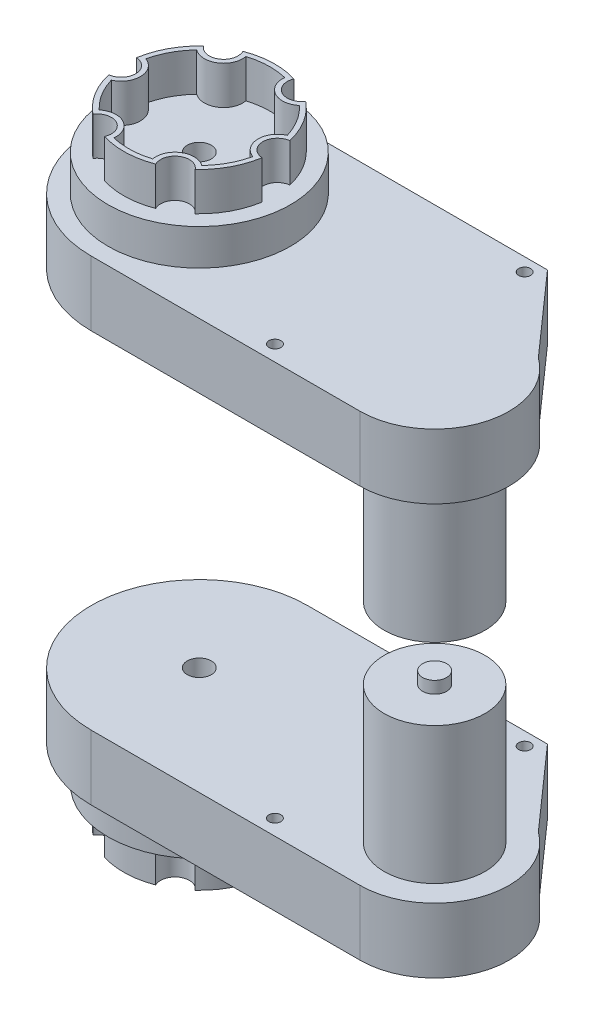
from build123d import *

# Parameters (mm, degrees)
SKETCH1_R                = 2.5
SKETCH1_R_2              = 5
BOSS_EXTRUDE1_DEPTH      = 27
SKETCH2_R                = 21
BOSS_EXTRUDE2_DEPTH      = 57
SKETCH4_R                = 38
SKETCH4_R_2              = 33
BOSS_EXTRUDE3_DEPTH      = 15
BOSS_EXTRUDE4_DEPTH      = 16
BOSS_EXTRUDE4_DEPTH_BACK = 15
SKETCH6_R                = 5
BOSS_EXTRUDE5_DEPTH      = 5
SKETCH7_R                = 33
BOSS_EXTRUDE6_DEPTH      = 15
SKETCH8_R                = 5
CUT_EXTRUDE1_DEPTH       = 65


with BuildPart() as part:
    # Sketch1 → Boss-Extrude1 (new body)
    with BuildSketch(Plane(origin=(0, 0, 0), x_dir=(1, 0, 0), z_dir=(0, 1, 0))):
        with BuildLine():
            Line((100, 45), (0, 45))
            ThreePointArc((0, 45), (-45, 0), (0, -45))
            Line((0, -45), (112, -45))
            ThreePointArc((112, -45), (141.550203848, -23.369389122), (129.862410225, 11.336422419))
            Line((129.862410225, 11.336422419), (100, 45))
        make_face()
        with Locations((70, -38.5)):
            Circle(SKETCH1_R, mode=Mode.SUBTRACT)
        with Locations((96, 39.5)):
            Circle(SKETCH1_R, mode=Mode.SUBTRACT)
        Circle(SKETCH1_R_2, mode=Mode.SUBTRACT)
    extrude(amount=BOSS_EXTRUDE1_DEPTH)

    # Sketch2 → Boss-Extrude2 (add)
    with BuildSketch(Plane(origin=(0, 27, 0), x_dir=(1, 0, 0), z_dir=(0, 1, 0))):
        with Locations((112, -14)):
            Circle(SKETCH2_R)
    extrude(amount=BOSS_EXTRUDE2_DEPTH)

    # Sketch4 → Boss-Extrude3 (add)
    with BuildSketch(Plane.XZ):
        Circle(SKETCH4_R)
        Circle(SKETCH4_R_2, mode=Mode.SUBTRACT)
    extrude(amount=BOSS_EXTRUDE3_DEPTH)

    # Sketch5 → Boss-Extrude4 (add, two sides)
    with BuildSketch(Plane.XZ.offset(15)) as boss_extrude4_sk:
        with BuildLine():
            ThreePointArc((31.106124527, 4.96578462), (27.77659984, 14.856328662), (21.39833694, 23.116253507))
            ThreePointArc((21.39833694, 23.116253507), (13.460014521, 21.658208815), (11.252566633, 29.421586364))
            ThreePointArc((11.252566633, 29.421586364), (1.022341892, 31.483405423), (-9.320094308, 30.089630142))
            ThreePointArc((-9.320094308, 30.089630142), (-12.026551774, 22.485818918), (-19.853557895, 24.455801744))
            ThreePointArc((-19.853557895, 24.455801744), (-26.754257948, 16.627076761), (-30.718431248, 6.973376635))
            ThreePointArc((-30.718431248, 6.973376635), (-25.486566295, 0.827610103), (-31.106124527, -4.96578462))
            ThreePointArc((-31.106124527, -4.96578462), (-27.77659984, -14.856328662), (-21.39833694, -23.116253507))
            ThreePointArc((-21.39833694, -23.116253507), (-13.460014521, -21.658208815), (-11.252566633, -29.421586364))
            ThreePointArc((-11.252566633, -29.421586364), (-1.022341892, -31.483405423), (9.320094308, -30.089630142))
            ThreePointArc((9.320094308, -30.089630142), (12.026551774, -22.485818918), (19.853557895, -24.455801744))
            ThreePointArc((19.853557895, -24.455801744), (26.754257948, -16.627076761), (30.718431248, -6.973376635))
            ThreePointArc((30.718431248, -6.973376635), (25.486566295, -0.827610103), (31.106124527, 4.96578462))
        make_face()
        with BuildLine():
            ThreePointArc((20.020308468, -21.666500614), (25.055574904, -15.571389348), (28.291265465, -8.357888394))
            ThreePointArc((28.291265465, -8.357888394), (23.487619919, -0.762699507), (28.773894177, 6.504845418))
            ThreePointArc((28.773894177, 6.504845418), (26.0130062, 13.913069699), (21.383776403, 20.322010401))
            ThreePointArc((21.383776403, 20.322010401), (12.404327108, 19.959525771), (8.753585708, 28.171346032))
            ThreePointArc((8.753585708, 28.171346032), (0.957431296, 29.484459047), (-6.907489061, 28.679898795))
            ThreePointArc((-6.907489061, 28.679898795), (-11.083292811, 20.722225278), (-20.020308468, 21.666500614))
            ThreePointArc((-20.020308468, 21.666500614), (-25.055574904, 15.571389348), (-28.291265465, 8.357888394))
            ThreePointArc((-28.291265465, 8.357888394), (-23.487619919, 0.762699507), (-28.773894177, -6.504845418))
            ThreePointArc((-28.773894177, -6.504845418), (-26.0130062, -13.913069699), (-21.383776403, -20.322010401))
            ThreePointArc((-21.383776403, -20.322010401), (-12.404327108, -19.959525771), (-8.753585708, -28.171346032))
            ThreePointArc((-8.753585708, -28.171346032), (-0.957431296, -29.484459047), (6.907489061, -28.679898795))
            ThreePointArc((6.907489061, -28.679898795), (11.083292811, -20.722225278), (20.020308468, -21.666500614))
        make_face(mode=Mode.SUBTRACT)
    extrude(amount=BOSS_EXTRUDE4_DEPTH)
    extrude(boss_extrude4_sk.sketch, amount=-BOSS_EXTRUDE4_DEPTH_BACK)

    # Sketch6 → Boss-Extrude5 (add)
    with BuildSketch(Plane(origin=(0, 84, 0), x_dir=(1, 0, 0), z_dir=(0, 1, 0))):
        with Locations((112, -14)):
            Circle(SKETCH6_R)
    extrude(amount=BOSS_EXTRUDE5_DEPTH)

    # Sketch7 → Boss-Extrude6 (add)
    with BuildSketch(Plane.XZ):
        Circle(SKETCH7_R)
    extrude(amount=BOSS_EXTRUDE6_DEPTH)

    # Sketch8 → Cut-Extrude1 (cut)
    with BuildSketch(Plane(origin=(0, 27, 0), x_dir=(1, 0, 0), z_dir=(0, 1, 0))):
        Circle(SKETCH8_R)
    extrude(amount=-CUT_EXTRUDE1_DEPTH, mode=Mode.SUBTRACT)


with BuildPart() as body_2:
    # Mirror2: mirrored copy
    add(part.part.mirror(Plane.ZX.offset(99)))


solid = Compound([part.part, body_2.part])
